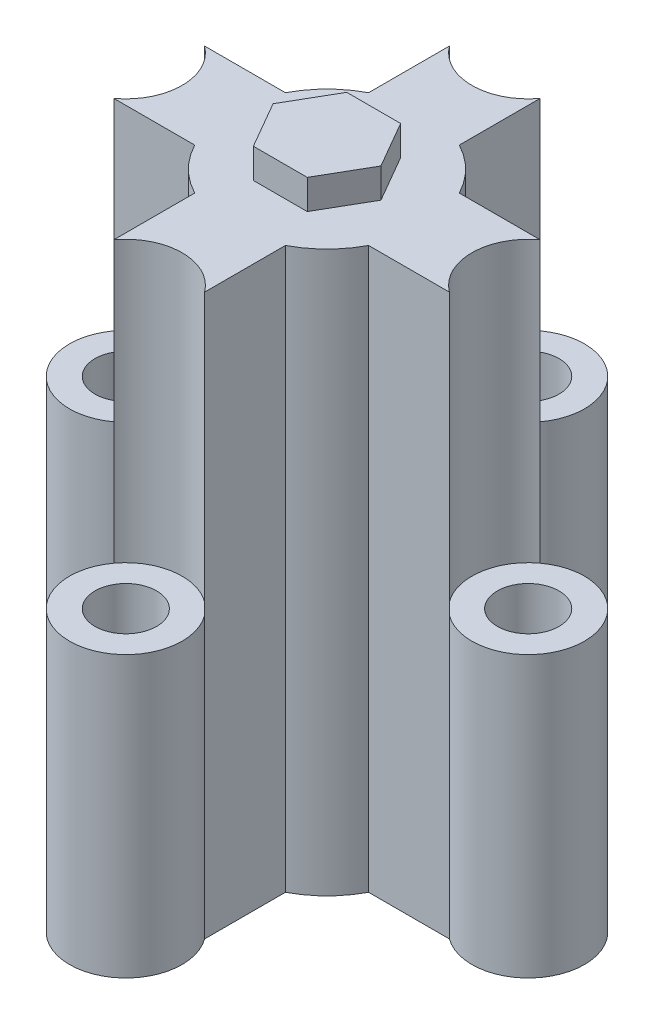
from build123d import *

# Parameters (mm, degrees)
BOSS_EXTRUDE1_DEPTH = 60
SKETCH1_3_R         = 6.03192879
SKETCH1_3_R_2       = 3.302
BOSS_EXTRUDE2_DEPTH = 30
BOSS_EXTRUDE3_DEPTH = 3.175


with BuildPart() as part:
    # Sketch1 → Boss-Extrude1 (new body)
    with BuildSketch(Plane(origin=(0, 0, 0), x_dir=(1, 0, 0), z_dir=(0, 1, 0))):
        with BuildLine():
            ThreePointArc((17.972934813, -4.85829948), (15.51607121, 0), (17.972934813, 4.85829948))
            Line((17.972934813, 4.85829948), (9.308433067, 4.85829948))
            ThreePointArc((9.308433067, 4.85829948), (7.424621202, 7.424621202), (4.85829948, 9.308433067))
            Line((4.85829948, 9.308433067), (4.85829948, 17.972934813))
            ThreePointArc((4.85829948, 17.972934813), (0, 15.51607121), (-4.85829948, 17.972934813))
            Line((-4.85829948, 17.972934813), (-4.85829948, 9.308433067))
            ThreePointArc((-4.85829948, 9.308433067), (-7.424621202, 7.424621202), (-9.308433067, 4.85829948))
            Line((-9.308433067, 4.85829948), (-17.972934813, 4.85829948))
            ThreePointArc((-17.972934813, 4.85829948), (-15.51607121, 0), (-17.972934813, -4.85829948))
            Line((-17.972934813, -4.85829948), (-9.308433067, -4.85829948))
            ThreePointArc((-9.308433067, -4.85829948), (-7.424621202, -7.424621202), (-4.85829948, -9.308433067))
            Line((-4.85829948, -9.308433067), (-4.85829948, -17.972934813))
            ThreePointArc((-4.85829948, -17.972934813), (0, -15.51607121), (4.85829948, -17.972934813))
            Line((4.85829948, -17.972934813), (4.85829948, -9.308433067))
            ThreePointArc((4.85829948, -9.308433067), (7.424621202, -7.424621202), (9.308433067, -4.85829948))
            Line((9.308433067, -4.85829948), (17.972934813, -4.85829948))
        make_face()
    extrude(amount=BOSS_EXTRUDE1_DEPTH)

    # Sketch1_3 → Boss-Extrude2 (add)
    with BuildSketch(Plane(origin=(0, 0, 0), x_dir=(1, 0, 0), z_dir=(0, 1, 0))):
        with Locations((21.548, 0)):
            Circle(SKETCH1_3_R)
        with Locations((21.548, 0)):
            Circle(SKETCH1_3_R_2, mode=Mode.SUBTRACT)
        with Locations((0, -21.548)):
            Circle(SKETCH1_3_R)
        with Locations((0, -21.548)):
            Circle(SKETCH1_3_R_2, mode=Mode.SUBTRACT)
        with Locations((-21.548, 0)):
            Circle(SKETCH1_3_R)
        with Locations((-21.548, 0)):
            Circle(SKETCH1_3_R_2, mode=Mode.SUBTRACT)
        with Locations((0, 21.548)):
            Circle(SKETCH1_3_R)
        with Locations((0, 21.548)):
            Circle(SKETCH1_3_R_2, mode=Mode.SUBTRACT)
    extrude(amount=BOSS_EXTRUDE2_DEPTH)

    # Sketch2 → Boss-Extrude3 (add)
    with BuildSketch(Plane(origin=(0, 60, 0), x_dir=(1, 0, 0), z_dir=(0, 1, 0))):
        Polygon((5.773502692, 0), (2.886751346, 5), (-2.886751346, 5), (-5.773502692, 0), (-2.886751346, -5), (2.886751346, -5), align=None)
    extrude(amount=BOSS_EXTRUDE3_DEPTH)


solid = part.part
